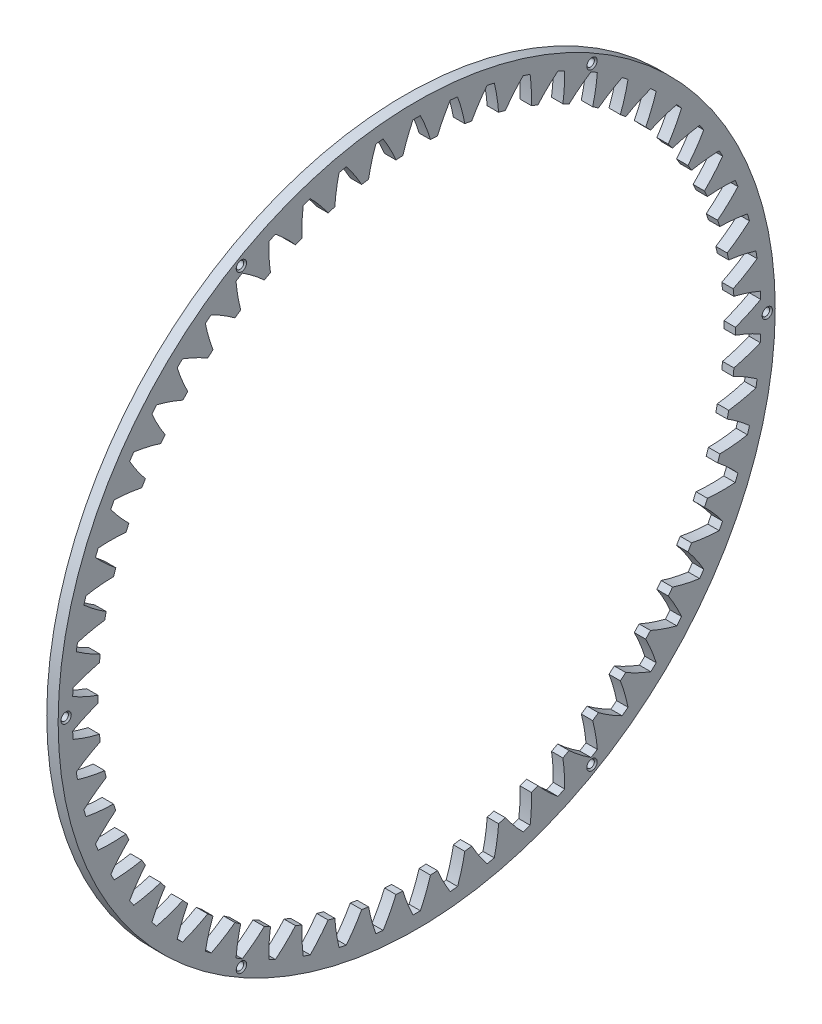
from build123d import *

# Parameters (mm, degrees)
BASPROSKE_W                     = 5
BASPROSKE_H                     = 17.5
TOOTHCUT_DEPTH                  = 223.794748592
TEETHCUTS_COUNT                 = 58
TEETHCUTS_ANGLE                 = 353.793103448
M4X0_7_TAPPED_HOLE1_D           = 3.3
M4X0_7_TAPPED_HOLE1_CSINK_D     = 4.55
M4X0_7_TAPPED_HOLE1_CSINK_ANGLE = 90


with BuildPart() as part:
    # BasProSke → Base-Revolve (revolve)
    with BuildSketch(Plane(origin=(0, 0, 0), x_dir=(1, 0, 0), z_dir=(0, 1, 0))):
        with Locations((2.5, 148.75)):
            Rectangle(BASPROSKE_W, BASPROSKE_H)
    revolve(axis=Axis((-10, 0, 0), (1, 0, 0)))

    # TooCutSke → ToothCut (cut, through all)
    with BuildSketch(Plane(origin=(0, 0, 0), x_dir=(0, 0, -1), z_dir=(1, 0, 0))):
        with BuildLine():
            ThreePointArc((6.05022475, 139.84378222), (4.07538244, 145.636660004), (1.61899396, 151.242334879))
            ThreePointArc((1.61899396, 151.242334879), (0, 151.251), (-1.61899396, 151.242334879))
            ThreePointArc((-1.61899396, 151.242334879), (-4.07538244, 145.636660004), (-6.05022475, 139.84378222))
            ThreePointArc((-6.05022475, 139.84378222), (0, 139.9746), (6.05022475, 139.84378222))
        make_face()
    toothcut = extrude(amount=TOOTHCUT_DEPTH, mode=Mode.SUBTRACT)

    # TeethCuts: ToothCut ×58 about axis
    teethcuts_axis = Axis((-10, 0, 0), (1, 0, 0))
    for i in range(1, TEETHCUTS_COUNT):
        add(toothcut.rotate(teethcuts_axis, i * TEETHCUTS_ANGLE / (TEETHCUTS_COUNT - 1)), mode=Mode.SUBTRACT)

    # M4x0.7 Tapped Hole1 (through all)
    with Locations(Plane(origin=(5, 0, 0), x_dir=(0, 0, -1), z_dir=(1, 0, 0))):
        with Locations((-154, 0), (154, 0), (77, 133.367912183), (-77, 133.367912183), (-77, -133.367912183), (77, -133.367912183)):
            CounterSinkHole(M4X0_7_TAPPED_HOLE1_D / 2, M4X0_7_TAPPED_HOLE1_CSINK_D / 2, counter_sink_angle=M4X0_7_TAPPED_HOLE1_CSINK_ANGLE)


solid = part.part
